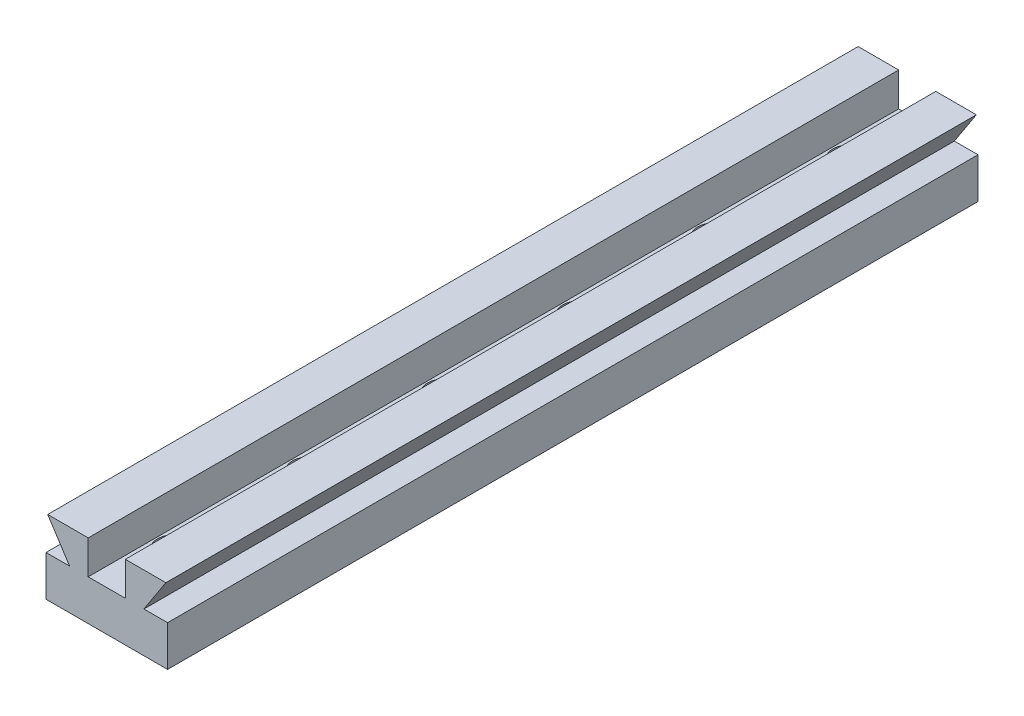
from build123d import *

# Parameters (mm, degrees)
BOSS_EXTRUDE1_DEPTH = 120
SKETCH2_R           = 2.5
CUT_EXTRUDE1_DEPTH  = 2.5
SKETCH3_R           = 1.5
CUT_EXTRUDE2_DEPTH  = 4.5


with BuildPart() as part:
    # Sketch1 → Boss-Extrude1 (new body)
    with BuildSketch(Plane.XY):
        Polygon((-9.600162866, 1.413680782), (-3.600162866, 1.413680782), (-3.600162866, -3.586319218), (1.899837134, -3.586319218), (1.899837134, 1.413680782), (7.899837134, 1.413680782), (4.649837134, -3.586319218), (8.149837134, -3.586319218), (8.149837134, -9.586319218), (-9.850162866, -9.586319218), (-9.850162866, -3.586319218), (-6.350162866, -3.586319218), align=None)
    extrude(amount=BOSS_EXTRUDE1_DEPTH)

    # Sketch2 → Cut-Extrude1 (cut)
    with BuildSketch(Plane(origin=(0, -3.586319218, 0), x_dir=(1, 0, 0), z_dir=(0, 1, 0))):
        with Locations((-0.850162866, -10)):
            Circle(SKETCH2_R)
        with Locations((-0.850162866, -30)):
            Circle(SKETCH2_R)
        with Locations((-0.850162866, -50)):
            Circle(SKETCH2_R)
        with Locations((-0.850162866, -70)):
            Circle(SKETCH2_R)
        with Locations((-0.850162866, -90)):
            Circle(SKETCH2_R)
        with Locations((-0.850162866, -110)):
            Circle(SKETCH2_R)
    extrude(amount=-CUT_EXTRUDE1_DEPTH, mode=Mode.SUBTRACT)

    # Sketch3 → Cut-Extrude2 (cut, through all)
    with BuildSketch(Plane(origin=(0, -6.086319218, 0), x_dir=(1, 0, 0), z_dir=(0, 1, 0))):
        with Locations((-0.850162866, -10)):
            Circle(SKETCH3_R)
        with Locations((-0.850162866, -30)):
            Circle(SKETCH3_R)
        with Locations((-0.850162866, -50)):
            Circle(SKETCH3_R)
        with Locations((-0.850162866, -70)):
            Circle(SKETCH3_R)
        with Locations((-0.850162866, -90)):
            Circle(SKETCH3_R)
        with Locations((-0.850162866, -110)):
            Circle(SKETCH3_R)
    extrude(amount=-CUT_EXTRUDE2_DEPTH, mode=Mode.SUBTRACT)


solid = part.part
